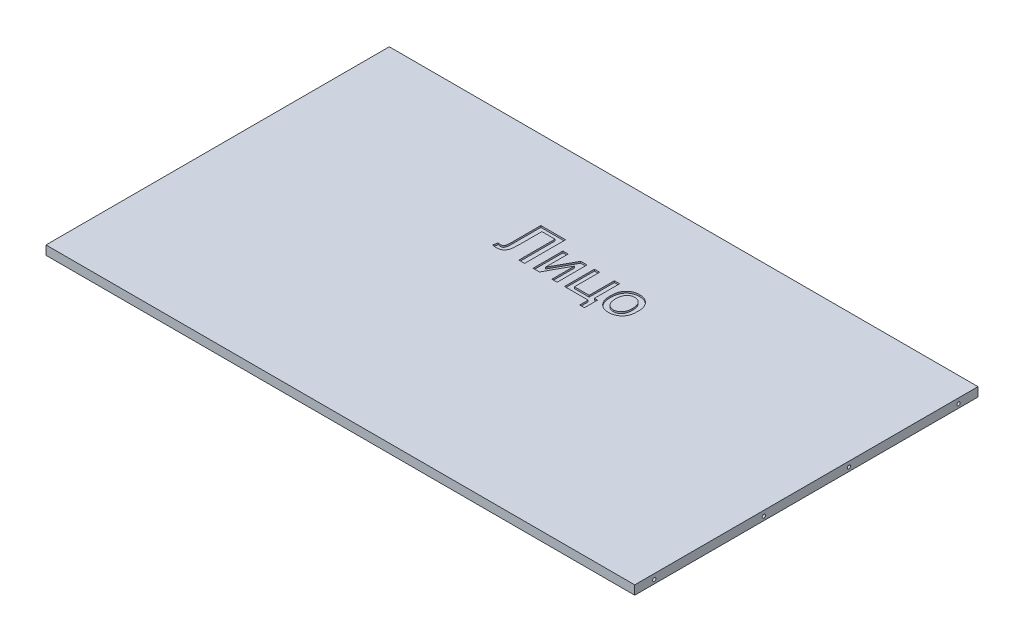
from build123d import *

# Parameters (mm, degrees)
SKETCH_1_W          = 359.3
SKETCH_1_H          = 209.5
EXTRUDE_1_DEPTH     = 5.5
CUT_EXTRUDE_1_DEPTH = 1
SKETCH_3_R          = 1
CUT_EXTRUDE_2_DEPTH = 2.5


with BuildPart() as part:
    # Эскиз1 → Бобышка-Вытянуть1 (new body)
    with BuildSketch(Plane(origin=(0, 0, 0), x_dir=(1, 0, 0), z_dir=(0, 1, 0))):
        Rectangle(SKETCH_1_W, SKETCH_1_H)
    extrude(amount=EXTRUDE_1_DEPTH)

    # Эскиз2 → Вырез-Вытянуть1 (cut)
    with BuildSketch(Plane(origin=(0, 5.5, 0), x_dir=(1, 0, 0), z_dir=(0, 1, 0))):
        with BuildLine():
            Line((-38.905327881, 56.519103922), (-23.841225317, 56.519103922))
            Line((-23.841225317, 56.519103922), (-23.841225317, 31.519103922))
            Line((-23.841225317, 31.519103922), (-27.366866343, 31.519103922))
            Line((-27.366866343, 31.519103922), (-27.366866343, 53.634488538))
            Line((-27.366866343, 53.634488538), (-35.379686855, 53.634488538))
            Line((-35.379686855, 53.634488538), (-35.379686855, 40.78392764))
            add(Edge.make_bspline(
                [(-35.379686855, 40.78392764), (-35.380094921, 40.468408642), (-35.380883076, 39.859001251), (-35.402445886, 38.977528889), (-35.43175272, 38.16279277), (-35.470297558, 37.412914169), (-35.524270765, 36.728087841), (-35.593967449, 36.108563595), (-35.674545658, 35.554116302), (-35.787170114, 34.912856182), (-35.992196575, 34.194680761), (-36.350845047, 33.423072198), (-36.820369332, 32.751469715), (-37.305907838, 32.28262503), (-37.739510744, 31.971308997), (-38.083129261, 31.762592751), (-38.448323706, 31.586675885), (-38.839131315, 31.448742308), (-39.245795076, 31.329657979), (-39.678195842, 31.259908952), (-40.127542538, 31.204887923), (-40.435920727, 31.200716361), (-40.593028202, 31.198591102)],
                knots=[0, 0, 0, 0, 0.000946528, 0.001828166, 0.002645024, 0.003392293, 0.004080599, 0.004705538, 0.005262216, 0.005761211, 0.006658247, 0.00749388, 0.008302531, 0.009102967, 0.009504671, 0.009902328, 0.01030776, 0.010718081, 0.011144586, 0.011576845, 0.01203034, 0.012501333, 0.012501333, 0.012501333, 0.012501333], degree=3))
            add(Edge.make_bspline(
                [(-40.593028202, 31.198591102), (-40.796813869, 31.202846952), (-41.225204727, 31.211793448), (-41.895328417, 31.276257926), (-42.625429969, 31.376695771), (-43.129105756, 31.470203333), (-43.392507368, 31.519103922)],
                knots=[0, 0, 0, 0, 0.000611306, 0.001285065, 0.002018102, 0.002821697, 0.002821697, 0.002821697, 0.002821697], degree=3))
            Line((-43.392507368, 31.519103922), (-42.751481727, 34.403719307))
            add(Edge.make_bspline(
                [(-42.751481727, 34.403719307), (-42.613594976, 34.354804397), (-42.350478481, 34.261464612), (-41.965163924, 34.162295703), (-41.611904714, 34.096357105), (-41.386213342, 34.087438323), (-41.279125958, 34.083206486)],
                knots=[0, 0, 0, 0, 0.00043868, 0.000837093, 0.001192767, 0.001513906, 0.001513906, 0.001513906, 0.001513906], degree=3))
            add(Edge.make_bspline(
                [(-41.279125958, 34.083206486), (-41.092676346, 34.093388276), (-40.737600061, 34.112778567), (-40.237632902, 34.271004561), (-39.817138982, 34.543485965), (-39.530064407, 34.859264099), (-39.343891544, 35.184056202), (-39.230627217, 35.509193766), (-39.122821435, 35.901454936), (-39.049900665, 36.367141536), (-38.984346245, 36.90150808), (-38.93339253, 37.506146128), (-38.912260737, 38.184614536), (-38.907718078, 38.660523317), (-38.905327881, 38.910930845)],
                knots=[0, 0, 0, 0, 0.000558612, 0.001063826, 0.001552794, 0.002045645, 0.002328276, 0.002670584, 0.003075118, 0.003547706, 0.004082533, 0.004690568, 0.005367113, 0.006118382, 0.006118382, 0.006118382, 0.006118382], degree=3))
            Line((-38.905327881, 38.910930845), (-38.905327881, 56.519103922))
        make_face()
        Polygon((-18.713020189, 49.788334691), (-15.507891984, 49.788334691), (-15.507891984, 35.856043025), (-7.835616343, 49.788334691), (-3.969430445, 49.788334691), (-3.969430445, 31.519103922), (-7.17455865, 31.519103922), (-7.17455865, 45.366259371), (-14.796754163, 31.519103922), (-18.713020189, 31.519103922), align=None)
        Polygon((0.517749042, 49.788334691), (3.722877247, 49.788334691), (3.722877247, 34.403719307), (12.697236222, 34.403719307), (12.697236222, 49.788334691), (15.902364427, 49.788334691), (15.902364427, 34.403719307), (17.82544135, 34.403719307), (17.82544135, 26.390898794), (14.940825965, 26.390898794), (14.940825965, 31.519103922), (0.517749042, 31.519103922), align=None)
        with BuildLine():
            add(Edge.make_bspline(
                [(19.428005452, 40.653719307), (19.436980417, 41.059682869), (19.454347629, 41.845252011), (19.578712315, 42.98517332), (19.791926504, 44.043469505), (20.091143372, 45.021134537), (20.478090089, 45.918476441), (20.956113849, 46.73046059), (21.512030856, 47.472004531), (21.955684305, 47.891158194), (22.177404491, 48.100634371)],
                knots=[0, 0, 0, 0, 0.001217781, 0.002356496, 0.003434906, 0.004451866, 0.005418529, 0.006359036, 0.007273544, 0.008187173, 0.008187173, 0.008187173, 0.008187173], degree=3))
            add(Edge.make_bspline(
                [(22.177404491, 48.100634371), (22.371328039, 48.261618735), (22.755636723, 48.580650074), (23.382899896, 48.985231575), (24.035950675, 49.332836499), (24.720559635, 49.621054068), (25.438890429, 49.841262714), (26.18870623, 49.994097345), (26.969048645, 50.093947761), (27.500606476, 50.103819403), (27.771354811, 50.108847512)],
                knots=[0, 0, 0, 0, 0.00075553, 0.001497274, 0.002234337, 0.002972828, 0.003722107, 0.00448428, 0.005266332, 0.006078187, 0.006078187, 0.006078187, 0.006078187], degree=3))
            add(Edge.make_bspline(
                [(27.771354811, 50.108847512), (28.070436488, 50.100409393), (28.655645222, 50.083898648), (29.514407583, 49.976230589), (30.327596629, 49.776145098), (31.105683134, 49.513912665), (31.836885031, 49.164443878), (32.532751365, 48.74780543), (33.176243025, 48.2428732), (33.779692974, 47.672142916), (34.324074879, 47.033878516), (34.798362628, 46.331216091), (35.200016532, 45.570225548), (35.531804778, 44.750185434), (35.786251866, 43.870522502), (35.963607972, 42.933116616), (36.077223587, 41.940238352), (36.088762699, 41.25834152), (36.094672119, 40.909127961)],
                knots=[0, 0, 0, 0, 0.000897329, 0.001755791, 0.002590268, 0.003405897, 0.00421461, 0.005016799, 0.005834211, 0.006663124, 0.007505081, 0.008345428, 0.009201212, 0.010081896, 0.010994757, 0.011943534, 0.012941223, 0.013988485, 0.013988485, 0.013988485, 0.013988485], degree=3))
            add(Edge.make_bspline(
                [(36.094672119, 40.909127961), (36.092445554, 40.625254509), (36.088119638, 40.073726399), (36.035829227, 39.270102307), (35.956810471, 38.513092112), (35.849264142, 37.801834258), (35.704394045, 37.137469164), (35.523739074, 36.520530257), (35.314233179, 35.947685633), (35.073444154, 35.41832387), (34.798693949, 34.928168736), (34.499374301, 34.466655732), (34.167960932, 34.034485014), (33.804878672, 33.632372815), (33.415027062, 33.257402842), (32.995746139, 32.908153612), (32.546261952, 32.589653132), (31.911679885, 32.202951018), (31.074110537, 31.797729137), (30.013287017, 31.450462519), (28.906566563, 31.238805643), (28.152890219, 31.212106881), (27.771354811, 31.198591102)],
                knots=[0, 0, 0, 0, 0.000851495, 0.00165434, 0.002414784, 0.003134406, 0.003811229, 0.004453056, 0.005061483, 0.005639665, 0.006195644, 0.006745706, 0.007288608, 0.007827615, 0.008369523, 0.008910063, 0.009463126, 0.010020547, 0.011138243, 0.01224524, 0.01336105, 0.014505027, 0.014505027, 0.014505027, 0.014505027], degree=3))
            add(Edge.make_bspline(
                [(27.771354811, 31.198591102), (27.467214439, 31.206839805), (26.871926501, 31.222984828), (26.001018392, 31.333140106), (25.174473442, 31.521892044), (24.39478491, 31.796955878), (23.655003746, 32.134609763), (22.962120756, 32.556118319), (22.314797091, 33.052297229), (21.718749578, 33.626347527), (21.173762776, 34.265478307), (20.708547382, 34.983412851), (20.310379866, 35.765343357), (19.985077728, 36.614642104), (19.736592267, 37.531334645), (19.558149132, 38.513007715), (19.445355779, 39.56101089), (19.43389456, 40.282828468), (19.428005452, 40.653719307)],
                knots=[0, 0, 0, 0, 0.000912338, 0.001785702, 0.002628775, 0.003450776, 0.004261904, 0.005064093, 0.005878446, 0.006703736, 0.007542455, 0.008392534, 0.009263785, 0.010170581, 0.011115809, 0.012108874, 0.013161332, 0.014273663, 0.014273663, 0.014273663, 0.014273663], degree=3))
        make_face()
        with BuildLine():
            add(Edge.make_bspline(
                [(22.633133657, 40.663735332), (22.638572984, 40.396529207), (22.649094446, 39.879663946), (22.711887206, 39.129452732), (22.826598011, 38.43297219), (22.986187119, 37.787691969), (23.190878969, 37.193520571), (23.441751695, 36.649452029), (23.736068326, 36.155025132), (24.080215268, 35.71830017), (24.454764421, 35.332283782), (24.858746856, 34.999314056), (25.286544396, 34.716581276), (25.738884097, 34.486049139), (26.213717559, 34.303908033), (26.712077883, 34.172763126), (27.234848853, 34.097459384), (27.590827739, 34.088002395), (27.771354811, 34.083206486)],
                knots=[0, 0, 0, 0, 0.000801673, 0.001550702, 0.002256281, 0.002917035, 0.003542636, 0.004138653, 0.004711518, 0.005264512, 0.005802821, 0.006322208, 0.006831968, 0.007338149, 0.007842245, 0.008354851, 0.008881074, 0.009422519, 0.009422519, 0.009422519, 0.009422519], degree=3))
            add(Edge.make_bspline(
                [(27.771354811, 34.083206486), (27.950330567, 34.08729649), (28.30346762, 34.095366476), (28.819433266, 34.18080395), (29.316005205, 34.303372584), (29.789080706, 34.484229739), (30.234723649, 34.722796736), (30.661569774, 35.004989838), (31.060967058, 35.342831142), (31.439801317, 35.728107904), (31.779030843, 36.171276854), (32.083310347, 36.663745634), (32.333312386, 37.216650691), (32.535422235, 37.821525306), (32.696778722, 38.479657305), (32.810955341, 39.191298014), (32.873381419, 39.95815681), (32.884049437, 40.486677351), (32.889543914, 40.758887576)],
                knots=[0, 0, 0, 0, 0.000536442, 0.001058454, 0.001564957, 0.002069053, 0.002573099, 0.003078685, 0.003601273, 0.004139582, 0.00469653, 0.005271994, 0.005872559, 0.006512371, 0.007182846, 0.007903252, 0.008672239, 0.009488929, 0.009488929, 0.009488929, 0.009488929], degree=3))
            add(Edge.make_bspline(
                [(32.889543914, 40.758887576), (32.884003125, 41.0160693), (32.873227192, 41.51624587), (32.81113729, 42.2432871), (32.694952105, 42.921016416), (32.538466814, 43.551344093), (32.32396426, 44.129079734), (32.077493328, 44.665176052), (31.773213208, 45.1490004), (31.428010932, 45.5832818), (31.051237132, 45.969763997), (30.650833024, 46.308941787), (30.222627661, 46.587485982), (29.776937049, 46.8242949), (29.30654292, 47.001235626), (28.815890596, 47.135079459), (28.301199691, 47.210133416), (27.950207003, 47.219473026), (27.771354811, 47.224232127)],
                knots=[0, 0, 0, 0, 0.00077164, 0.001500715, 0.002186538, 0.002832727, 0.003445856, 0.004032799, 0.004599745, 0.005155837, 0.005694146, 0.006216734, 0.006726495, 0.007223778, 0.007727874, 0.008230799, 0.00874711, 0.009283552, 0.009283552, 0.009283552, 0.009283552], degree=3))
            add(Edge.make_bspline(
                [(27.771354811, 47.224232127), (27.590843075, 47.219396398), (27.23489443, 47.20986089), (26.711903433, 47.135128442), (26.214919586, 47.002043796), (25.737666518, 46.827843783), (25.28699696, 46.595095766), (24.856721904, 46.313915181), (24.458294126, 45.974637431), (24.07807896, 45.594590757), (23.7378803, 45.157816449), (23.441560483, 44.668358417), (23.189880982, 44.127689844), (22.986333567, 43.534718029), (22.8265556, 42.88950594), (22.711896861, 42.193005438), (22.649242344, 41.444464112), (22.638612426, 40.929271081), (22.633133657, 40.663735332)],
                knots=[0, 0, 0, 0, 0.000541445, 0.001067667, 0.001580274, 0.0020826, 0.002588781, 0.003098542, 0.00362113, 0.004155863, 0.004708857, 0.005277437, 0.005868913, 0.006494514, 0.007155268, 0.007860847, 0.008609876, 0.009406544, 0.009406544, 0.009406544, 0.009406544], degree=3))
        make_face(mode=Mode.SUBTRACT)
    extrude(amount=-CUT_EXTRUDE_1_DEPTH, mode=Mode.SUBTRACT)

    # Эскиз3 → Вырез-Вытянуть2 (cut)
    with BuildSketch(Plane.ZY.offset(179.65)):
        with Locations((92.85, 2.4)):
            Circle(SKETCH_3_R)
        with Locations((25.950000009, 2.401120989)):
            Circle(SKETCH_3_R)
        with Locations((-25.949999983, 2.401990635)):
            Circle(SKETCH_3_R)
        with Locations((-92.849999974, 2.403111624)):
            Circle(SKETCH_3_R)
    cut_extrude_2 = extrude(amount=-CUT_EXTRUDE_2_DEPTH, mode=Mode.SUBTRACT)

    # Зеркальное отражение1: Вырез-Вытянуть2 across plane
    add(cut_extrude_2.mirror(Plane(origin=(0, 0, 0), x_dir=(0, 0, 1), z_dir=(1, 0, 0))), mode=Mode.SUBTRACT)


solid = part.part
